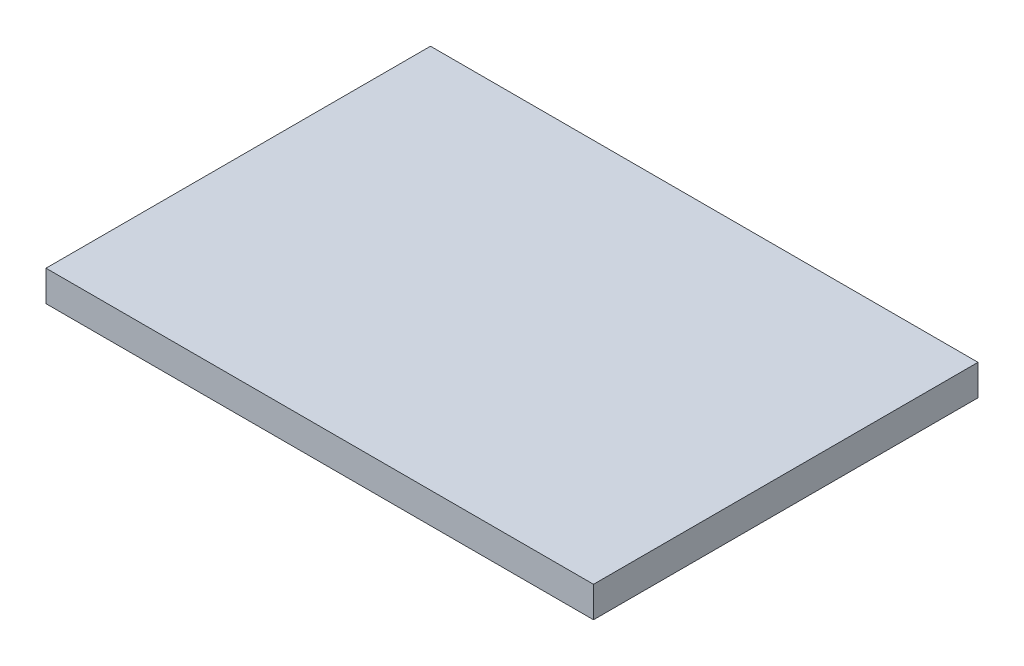
from build123d import *

# Parameters (mm, degrees)
SKETCH1_W           = 35.6
SKETCH1_H           = 25
BOSS_EXTRUDE1_DEPTH = 2


with BuildPart() as part:
    # Sketch1 → Boss-Extrude1 (new body)
    with BuildSketch(Plane(origin=(0, 0, 0), x_dir=(1, 0, 0), z_dir=(0, 1, 0))):
        with Locations((-10.514418605, -5.631162791)):
            Rectangle(SKETCH1_W, SKETCH1_H)
    extrude(amount=BOSS_EXTRUDE1_DEPTH)


solid = part.part
